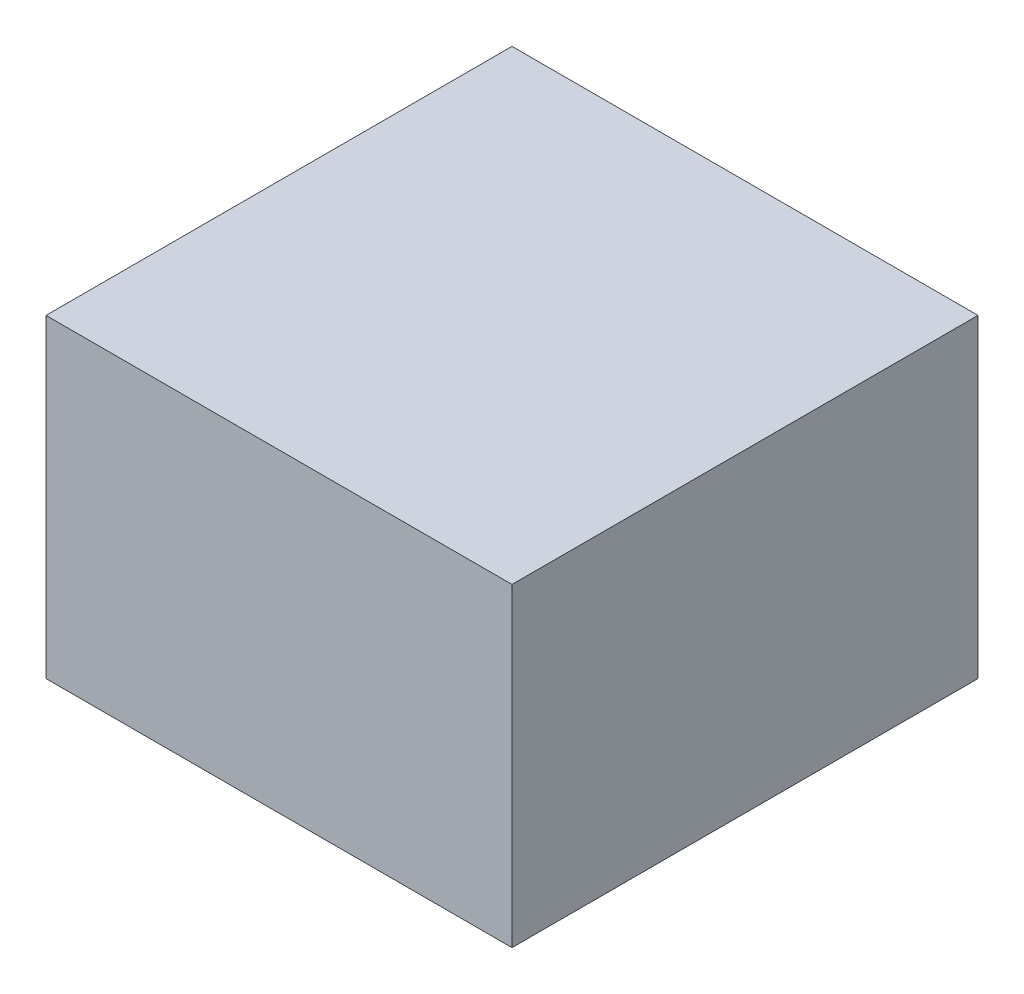
from build123d import *

# Parameters (mm, degrees)
ESQUISSE1_W        = 40
ESQUISSE1_H        = 40
BOSS_EXTRU_1_DEPTH = 27


with BuildPart() as part:
    # Esquisse1 → Boss.-Extru.1 (new body)
    with BuildSketch(Plane(origin=(0, 0, 0), x_dir=(1, 0, 0), z_dir=(0, 1, 0))):
        with Locations((2.697674419, -1.209302326)):
            Rectangle(ESQUISSE1_W, ESQUISSE1_H)
    extrude(amount=BOSS_EXTRU_1_DEPTH)


solid = part.part
